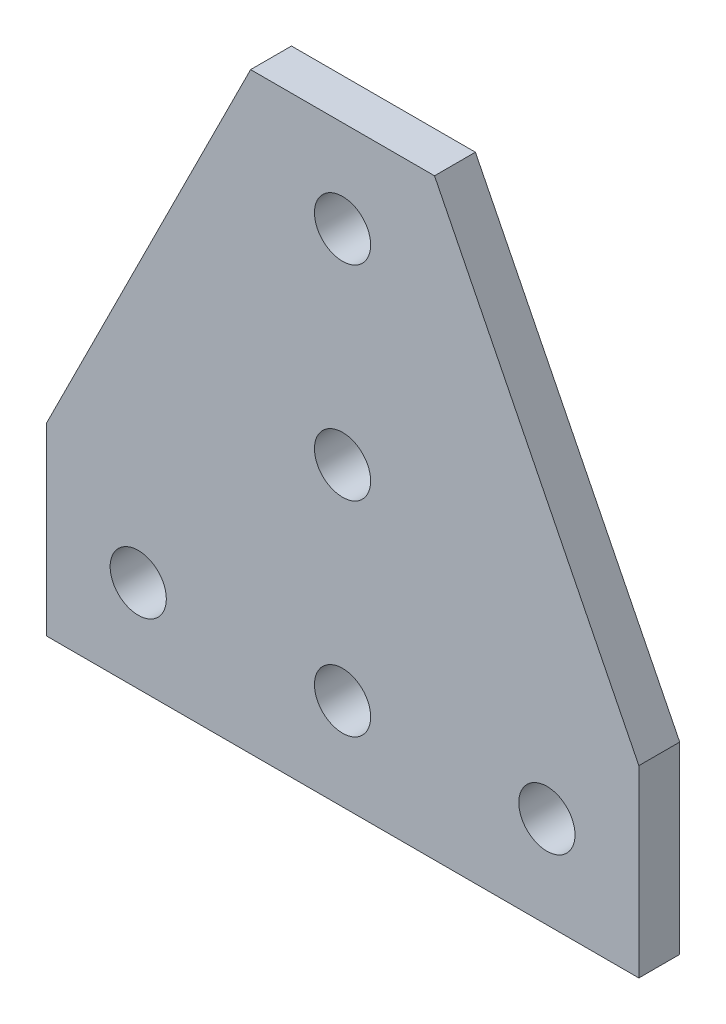
from build123d import *

# Parameters (mm, degrees)
SKETCH1_R           = 2.75
BOSS_EXTRUDE1_DEPTH = 2


with BuildPart() as part:
    # Sketch1 → Boss-Extrude1 (new body, symmetric)
    with BuildSketch(Plane.XY):
        Polygon((-29, 0), (29, 0), (29, 18), (9, 58), (-9, 58), (-29, 18), align=None)
        with Locations((0, 9)):
            Circle(SKETCH1_R, mode=Mode.SUBTRACT)
        with Locations((-20, 9)):
            Circle(SKETCH1_R, mode=Mode.SUBTRACT)
        with Locations((20, 9)):
            Circle(SKETCH1_R, mode=Mode.SUBTRACT)
        with Locations((0, 29)):
            Circle(SKETCH1_R, mode=Mode.SUBTRACT)
        with Locations((0, 49)):
            Circle(SKETCH1_R, mode=Mode.SUBTRACT)
    extrude(amount=BOSS_EXTRUDE1_DEPTH, both=True)


solid = part.part
